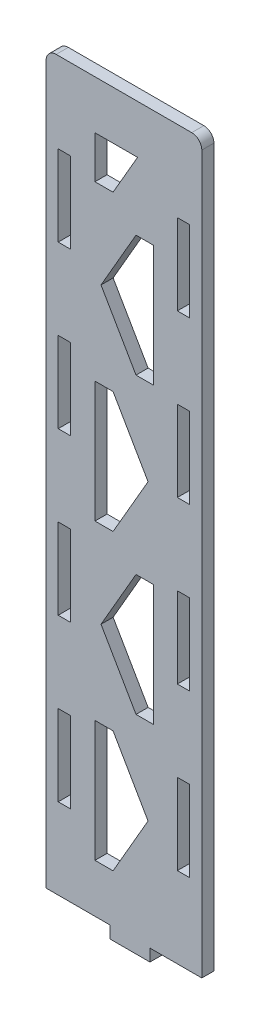
from build123d import *

# Parameters (mm, degrees)
SKETCH1_W               = 38.55
SKETCH1_H               = 180
SKETCH1_W_2             = 3.05
SKETCH1_H_2             = 20
SKETCH1_W_3             = 9.833333334
SKETCH1_H_3             = 3
BOSS_EXTRUDE1_DEPTH     = 3
CUT_EXTRUDE4_DEPTH      = 1
CUT_EXTRUDE4_DEPTH_BACK = 4
FILLET1_R               = 2.5


with BuildPart() as part:
    # Sketch1 → Boss-Extrude1 (new body)
    with BuildSketch(Plane.XY):
        Rectangle(SKETCH1_W, SKETCH1_H)
        with Locations((14.75, -20)):
            Rectangle(SKETCH1_W_2, SKETCH1_H_2, mode=Mode.SUBTRACT)
        with Locations((14.75, 20)):
            Rectangle(SKETCH1_W_2, SKETCH1_H_2, mode=Mode.SUBTRACT)
        with Locations((14.75, 60)):
            Rectangle(SKETCH1_W_2, SKETCH1_H_2, mode=Mode.SUBTRACT)
        with Locations((14.75, -60)):
            Rectangle(SKETCH1_W_2, SKETCH1_H_2, mode=Mode.SUBTRACT)
        with Locations((-14.75, 60)):
            Rectangle(SKETCH1_W_2, SKETCH1_H_2, mode=Mode.SUBTRACT)
        with Locations((-14.75, 20)):
            Rectangle(SKETCH1_W_2, SKETCH1_H_2, mode=Mode.SUBTRACT)
        with Locations((-14.75, -20)):
            Rectangle(SKETCH1_W_2, SKETCH1_H_2, mode=Mode.SUBTRACT)
        with Locations((-14.75, -60)):
            Rectangle(SKETCH1_W_2, SKETCH1_H_2, mode=Mode.SUBTRACT)
        with Locations((1.525, -91.5)):
            Rectangle(SKETCH1_W_3, SKETCH1_H_3)
    extrude(amount=BOSS_EXTRUDE1_DEPTH)

    # Sketch3 → Cut-Extrude4 (cut, two sides)
    with BuildSketch(Plane.XY.offset(3)) as cut_extrude4_sk:
        Polygon((2.985254038, 31.119200877), (-5.675, 46.119200877), (2.985254038, 61.119200877), (7.325, 61.119200877), (7.325, 31.119200877), align=None)
        Polygon((2.985254038, -41.626933041), (-5.675, -26.626933041), (2.985254038, -11.626933041), (7.325, -11.626933041), (7.325, -41.626933041), align=None)
        Polygon((-7.175, 67.492267836), (-2.694237886, 67.492267836), (3.372404107, 78), (-7.175, 78), align=None)
        Polygon((-7.175, 24.746133918), (-2.694237886, 24.746133918), (5.966016151, 9.746133918), (-2.694237886, -5.253866082), (-7.175, -5.253866082), align=None)
        Polygon((-7.175, -78), (-7.175, -48), (-2.694237886, -48), (5.966016151, -63), (-2.694237886, -78), align=None)
    extrude(amount=CUT_EXTRUDE4_DEPTH, mode=Mode.SUBTRACT)
    extrude(cut_extrude4_sk.sketch, amount=-CUT_EXTRUDE4_DEPTH_BACK, mode=Mode.SUBTRACT)

    # Fillet1
    fillet1_edges = [part.edges().sort_by_distance(p)[0] for p in [
        (-19.275, 90, 1.5),
        (19.275, 90, 1.5),
    ]]
    fillet(fillet1_edges, radius=FILLET1_R)


solid = part.part
